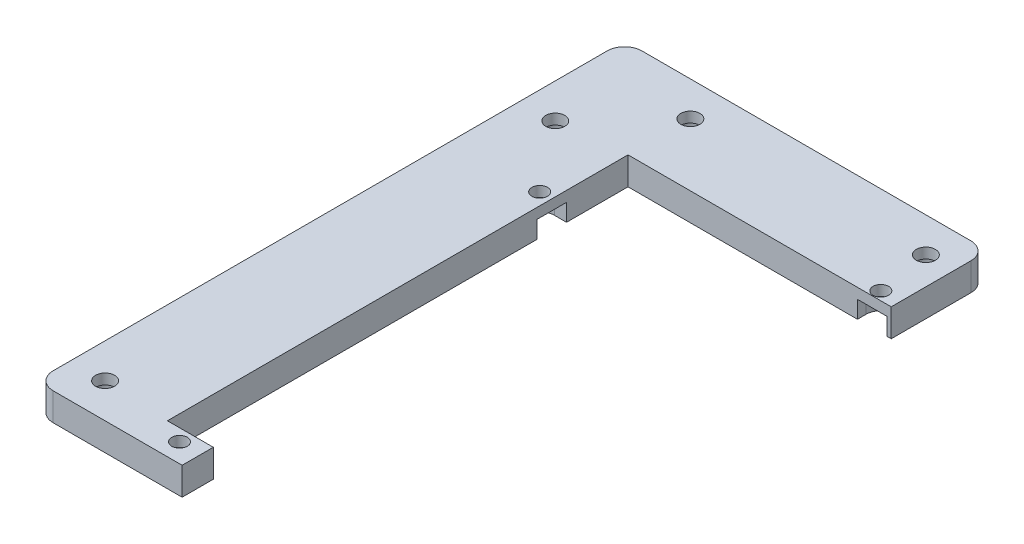
from build123d import *

# Parameters (mm, degrees)
BOSS_EXTRUDE1_DEPTH      = 4
BOSS_EXTRUDE1_DEPTH_BACK = 4
SKETCH2_R                = 2.75
SKETCH2_R_2              = 2.25
SKETCH3_R                = 4.25
CUT_EXTRUDE1_DEPTH       = 5


with BuildPart() as part:
    # Sketch2 → Boss-Extrude1 (new, two sides: drawn at the far end of the back side and taken through both)
    with BuildSketch(Plane(origin=(0, 0, 0), x_dir=(1, 0, 0), z_dir=(0, 1, 0)).offset(-BOSS_EXTRUDE1_DEPTH_BACK)):
        with BuildLine():
            ThreePointArc((-52.5, -80), (-51.035533906, -83.535533906), (-47.5, -85))
            Line((-47.5, -85), (-23.5, -85))
            Line((-23.5, -85), (-10.25, -85))
            Line((-10.25, -85), (-10.25, -76))
            Line((-10.25, -76), (-23.5, -76))
            Line((-23.5, -76), (-23.5, -62.428663753))
            Line((-23.5, -62.428663753), (-23.5, 57))
            Line((-23.5, 57), (52.5, 57))
            Line((52.5, 57), (52.5, 80))
            ThreePointArc((52.5, 80), (51.035533906, 83.535533906), (47.5, 85))
            Line((47.5, 85), (-47.5, 85))
            ThreePointArc((-47.5, 85), (-51.035533906, 83.535533906), (-52.5, 80))
            Line((-52.5, 80), (-52.5, -80))
        make_face()
        with Locations((-42.5, -75)):
            Circle(SKETCH2_R, mode=Mode.SUBTRACT)
        with Locations((-16.5, -79.5)):
            Circle(SKETCH2_R_2, mode=Mode.SUBTRACT)
        with Locations((-27, 35)):
            Circle(SKETCH2_R_2, mode=Mode.SUBTRACT)
        with Locations((-42.5, 55)):
            Circle(SKETCH2_R, mode=Mode.SUBTRACT)
        with Locations((-23.5, 75)):
            Circle(SKETCH2_R, mode=Mode.SUBTRACT)
        with Locations((47, 59.5)):
            Circle(SKETCH2_R_2, mode=Mode.SUBTRACT)
        with Locations((44.5, 75)):
            Circle(SKETCH2_R, mode=Mode.SUBTRACT)
    extrude(amount=BOSS_EXTRUDE1_DEPTH + BOSS_EXTRUDE1_DEPTH_BACK)

    # Sketch3 → Cut-Extrude1 (cut)
    with BuildSketch(Plane.XZ.offset(4)):
        with Locations((-23.5, -75)):
            Circle(SKETCH3_R)
        with Locations((-42.5, -55)):
            Circle(SKETCH3_R)
        with Locations((-42.5, 75)):
            Circle(SKETCH3_R)
        with Locations((44.5, -75)):
            Circle(SKETCH3_R)
        with BuildLine():
            Line((-27, -30.75), (-23.5, -30.75))
            Line((-23.5, -30.75), (-23.5, -39.25))
            Line((-23.5, -39.25), (-27, -39.25))
            ThreePointArc((-27, -39.25), (-31.25, -35), (-27, -30.75))
        make_face()
        with BuildLine():
            Line((51.25, -59.5), (51.25, -57))
            Line((51.25, -57), (42.75, -57))
            Line((42.75, -57), (42.75, -59.5))
            ThreePointArc((42.75, -59.5), (47, -63.75), (51.25, -59.5))
        make_face()
        with BuildLine():
            Line((-12.25, 79.5), (-12.25, 76))
            Line((-12.25, 76), (-20.75, 76))
            Line((-20.75, 76), (-20.75, 79.5))
            ThreePointArc((-20.75, 79.5), (-16.5, 83.75), (-12.25, 79.5))
        make_face()
    extrude(amount=-CUT_EXTRUDE1_DEPTH, mode=Mode.SUBTRACT)


solid = part.part
